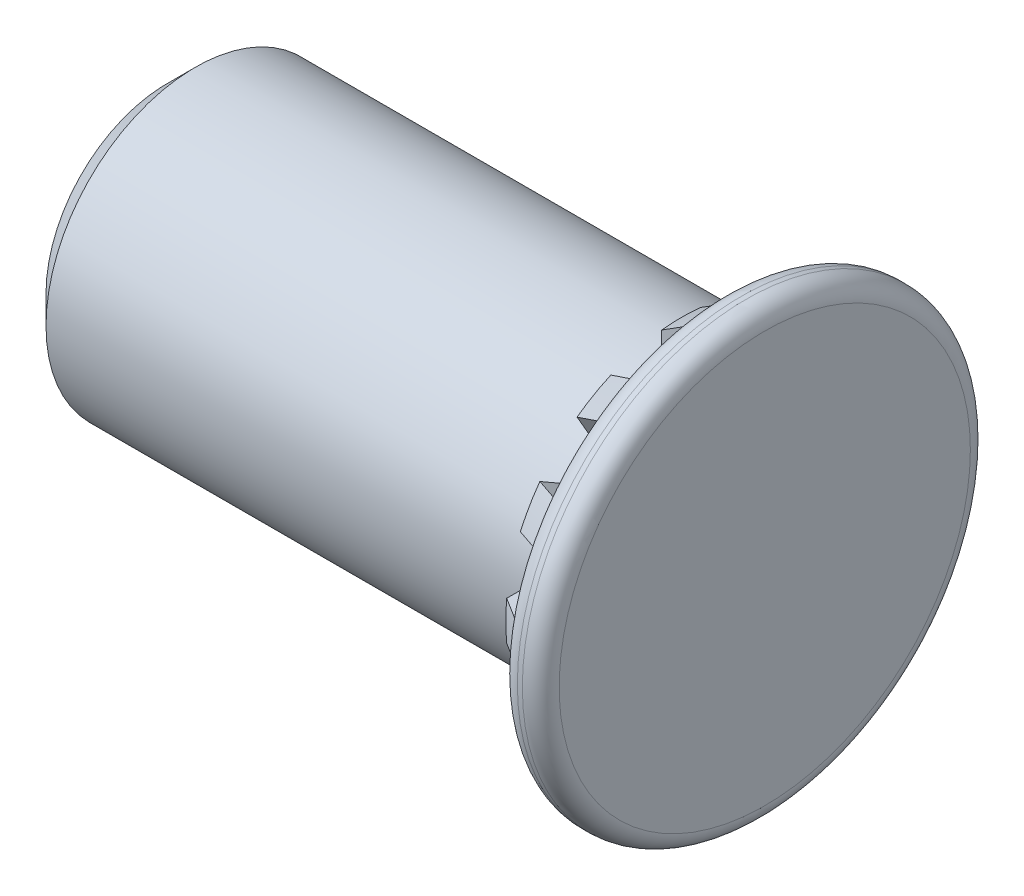
from build123d import *

# Parameters (mm, degrees)
CHAMFER1_SIZE       = 0.281
FILLET1_R           = 0.185
BOSS_EXTRUDE1_DEPTH = 0.42
CIRPATTERN1_COUNT   = 12


with BuildPart() as part:
    # Sketch1 → Revolve1 (revolve)
    with BuildSketch(Plane.XY, mode=Mode.PRIVATE) as revolve1_sk:
        Polygon((0, 0), (0, 2.25), (-0.42, 2.25), (-0.42, 1.763), (-0.578, 1.763), (-0.578, 1.5), (-6, 1.5), (-6, 0), align=None)
    revolve(revolve1_sk.sketch.rotate(Axis((99.339643322, 0, 0), (-1, 0, 0)), 90), axis=Axis((99.339643322, 0, 0), (-1, 0, 0)))

    # Chamfer1
    chamfer1_edges = [part.edges().sort_by_distance(p)[0] for p in [
        (-6, 0, 1.5),
    ]]
    chamfer(chamfer1_edges, length=CHAMFER1_SIZE)

    # Fillet1
    fillet1_edges = [part.edges().sort_by_distance(p)[0] for p in [
        (-0.42, 0, 2.25),
        (0, 0, 2.25),
    ]]
    fillet(fillet1_edges, radius=FILLET1_R)

    # Sketch2 → Boss-Extrude1 (add)
    with BuildSketch(Plane.ZY.offset(0.42)):
        with BuildLine():
            Line((0.196, 1.75207106), (0.196, 2.015492248))
            ThreePointArc((0.196, 2.015492248), (0.098115235, 2.022621665), (0, 2.025))
            Line((0, 2.025), (0, 1.763))
            ThreePointArc((0, 1.763), (0.098152231, 1.760265645), (0.196, 1.75207106))
        make_face()
        with BuildLine():
            Line((0.196, 1.487139536), (0.196, 1.75207106))
            ThreePointArc((0.196, 1.75207106), (0.098152231, 1.760265645), (0, 1.763))
            Line((0, 1.763), (0, 1.5))
            ThreePointArc((0, 1.5), (0.098210732, 1.496781431), (0.196, 1.487139536))
        make_face()
        with BuildLine():
            Line((0, 1.763), (0, 2.025))
            ThreePointArc((0, 2.025), (-0.098115235, 2.022621665), (-0.196, 2.015492248))
            Line((-0.196, 2.015492248), (-0.196, 1.75207106))
            ThreePointArc((-0.196, 1.75207106), (-0.098152231, 1.760265645), (0, 1.763))
        make_face()
        with BuildLine():
            Line((0, 1.5), (0, 1.763))
            ThreePointArc((0, 1.763), (-0.098152231, 1.760265645), (-0.196, 1.75207106))
            Line((-0.196, 1.75207106), (-0.196, 1.487139536))
            ThreePointArc((-0.196, 1.487139536), (-0.098210732, 1.496781431), (0, 1.5))
        make_face()
    boss_extrude1 = extrude(amount=BOSS_EXTRUDE1_DEPTH)

    # Sketch3 → Cut-Revolve1 (revolve, cut)
    with BuildSketch(Plane.XY):
        Polygon((-0.42, 2.025), (-0.84, 1.762), (-0.84, 2.025), align=None)
    cut_revolve1 = revolve(axis=Axis((-6.625194775, 0, 0), (0.9999630325652946, -0.008598459328248705, 0)), mode=Mode.SUBTRACT)

    # CirPattern1: Boss-Extrude1, Cut-Revolve1 ×12 about axis
    cirpattern1_axis = Axis((0, 0, 0), (1, 0, 0))
    add([boss_extrude1.rotate(cirpattern1_axis, i * 360 / CIRPATTERN1_COUNT) for i in range(1, CIRPATTERN1_COUNT)])
    add([cut_revolve1.rotate(cirpattern1_axis, i * 360 / CIRPATTERN1_COUNT) for i in range(1, CIRPATTERN1_COUNT)], mode=Mode.SUBTRACT)


solid = part.part
